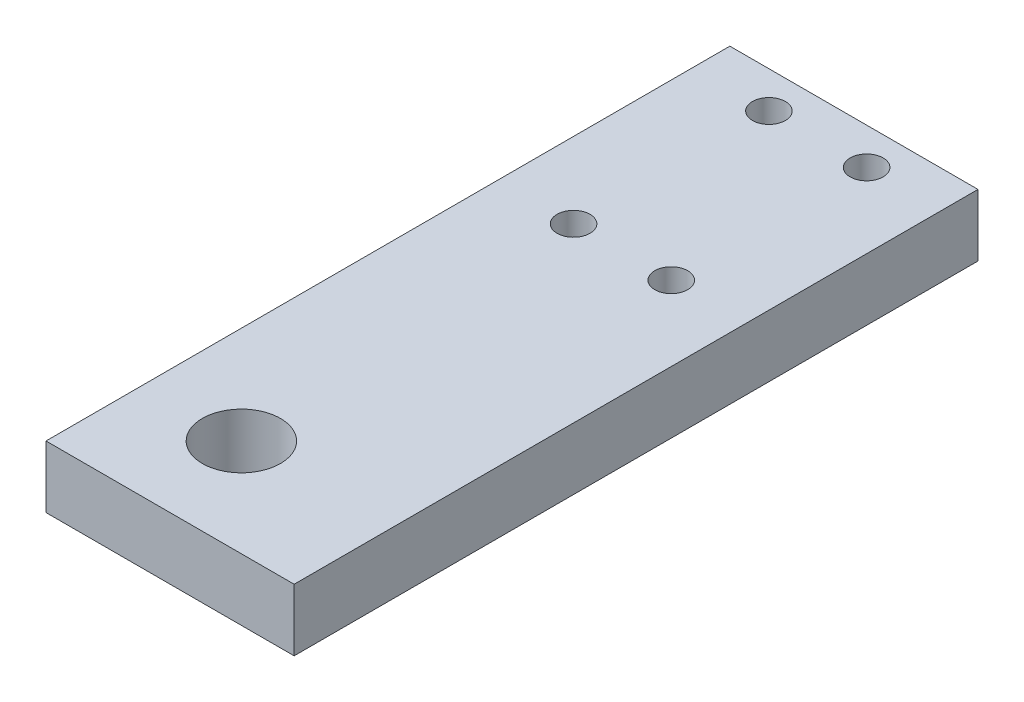
from build123d import *

# Parameters (mm, degrees)
SKETCH2_W           = 101.6
SKETCH2_H           = 280
BOSS_EXTRUDE1_DEPTH = 25.4
SKETCH3_R           = 6.75
CUT_EXTRUDE1_DEPTH  = 25.4
SKETCH4_R           = 16
CUT_EXTRUDE2_DEPTH  = 25.4


with BuildPart() as part:
    # Sketch2 → Boss-Extrude1 (new body)
    with BuildSketch(Plane(origin=(0, 0, 0), x_dir=(1, 0, 0), z_dir=(0, 1, 0))):
        with Locations((50.8, 140)):
            Rectangle(SKETCH2_W, SKETCH2_H)
    extrude(amount=BOSS_EXTRUDE1_DEPTH)

    # Sketch3 → Cut-Extrude1 (cut)
    with BuildSketch(Plane(origin=(0, 25.4, 0), x_dir=(1, 0, 0), z_dir=(0, 1, 0))):
        with Locations((71, 265)):
            Circle(SKETCH3_R)
        with Locations((31, 265)):
            Circle(SKETCH3_R)
        with Locations((31, 185)):
            Circle(SKETCH3_R)
        with Locations((71, 185)):
            Circle(SKETCH3_R)
    extrude(amount=-CUT_EXTRUDE1_DEPTH, mode=Mode.SUBTRACT)

    # Sketch4 → Cut-Extrude2 (cut)
    with BuildSketch(Plane(origin=(0, 25.4, 0), x_dir=(1, 0, 0), z_dir=(0, 1, 0))):
        with Locations((40, 40)):
            Circle(SKETCH4_R)
    extrude(amount=-CUT_EXTRUDE2_DEPTH, mode=Mode.SUBTRACT)


solid = part.part
